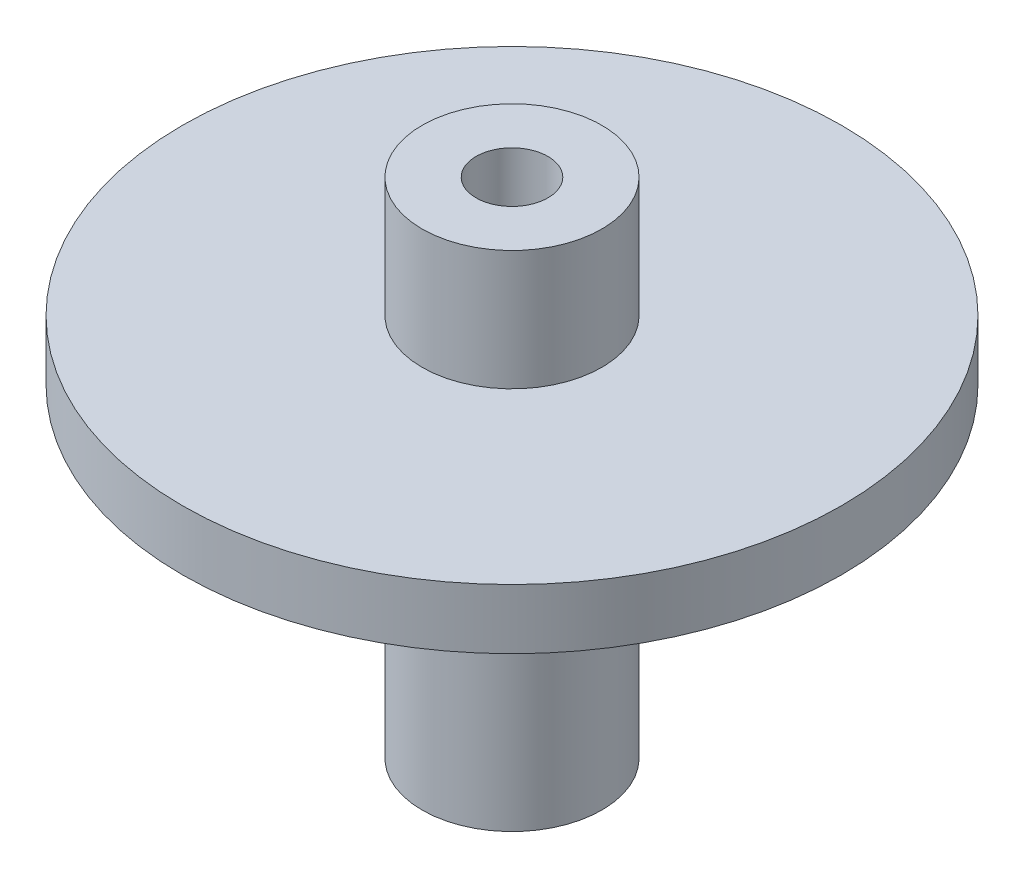
from build123d import *

# Parameters (mm, degrees)
SKIZZE2_R                       = 7.5
SKIZZE2_R_2                     = 3
AUFSATZ_LINEAR_AUSTRAGEN1_DEPTH = 10


with BuildPart() as part:
    # Skizze1 → Rotation1 (revolve)
    with BuildSketch(Plane(origin=(0, 0, 0), x_dir=(0, 0, -1), z_dir=(1, 0, 0))):
        Polygon((-3, 0), (-27.5, 0), (-27.5, -5), (-7.5, -5), (-7.5, -32), (-3, -32), align=None)
    revolve(axis=Axis((0, 21.68541583, 0), (0, -1, 0)))

    # Skizze2 → Aufsatz-Linear austragen1 (add)
    with BuildSketch(Plane(origin=(0, 0, 0), x_dir=(1, 0, 0), z_dir=(0, 1, 0))):
        Circle(SKIZZE2_R)
        Circle(SKIZZE2_R_2, mode=Mode.SUBTRACT)
    extrude(amount=AUFSATZ_LINEAR_AUSTRAGEN1_DEPTH)


solid = part.part
